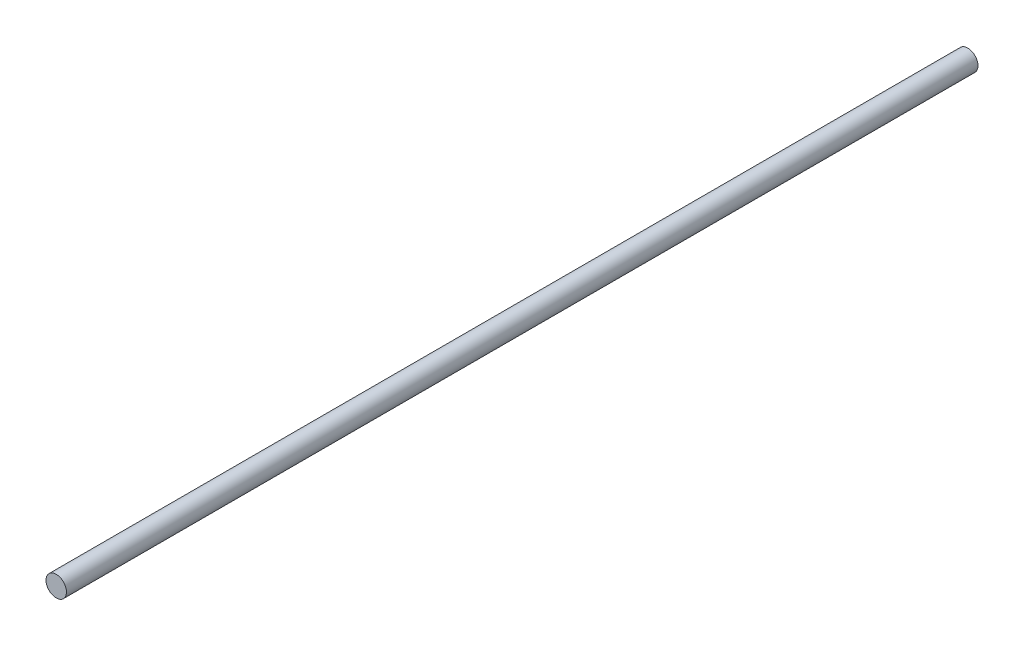
from build123d import *

# Parameters (mm, degrees)
CROQUIS1_R              = 4
SALIENTE_EXTRUIR1_DEPTH = 356


with BuildPart() as part:
    # Croquis1 → Saliente-Extruir1 (new body)
    with BuildSketch(Plane.XY):
        Circle(CROQUIS1_R)
    extrude(amount=SALIENTE_EXTRUIR1_DEPTH)


solid = part.part
